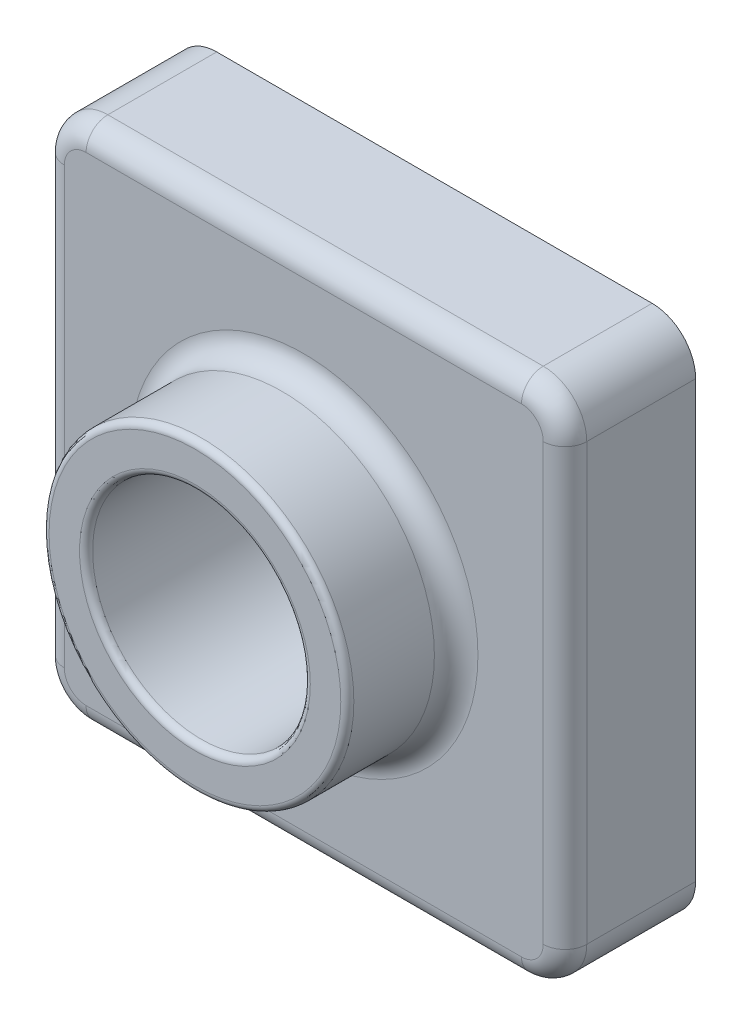
from build123d import *
from OCP.BRepFilletAPI import BRepFilletAPI_MakeFillet

# Parameters (mm, degrees)
SKETCH1_W           = 120
SKETCH1_H           = 120
BOSS_EXTRUDE1_DEPTH = 30
SKETCH3_R           = 35
BOSS_EXTRUDE2_DEPTH = 25
SKETCH4_R           = 25
CUT_EXTRUDE1_DEPTH  = 179.395627749
FILLET1_R1          = 5
FILLET1_R2          = 10
FILLET2_R           = 1.5
SHELL1_T            = -2


with BuildPart() as part:
    # Sketch1 → Boss-Extrude1 (new body)
    with BuildSketch(Plane.XY):
        with Locations((60, 60)):
            Rectangle(SKETCH1_W, SKETCH1_H)
    extrude(amount=BOSS_EXTRUDE1_DEPTH)

    # Sketch3 → Boss-Extrude2 (add)
    with BuildSketch(Plane.XY.offset(30)):
        with Locations((60, 60)):
            Circle(SKETCH3_R)
    extrude(amount=BOSS_EXTRUDE2_DEPTH)

    # Sketch4 → Cut-Extrude1 (cut, through all)
    with BuildSketch(Plane.XY.offset(55)):
        with Locations((60, 60)):
            Circle(SKETCH4_R)
    extrude(amount=-CUT_EXTRUDE1_DEPTH, mode=Mode.SUBTRACT)

    # Fillet1: one fillet with a radius per group of edges: ONE call of the kernel's fillet builder (fillet() takes one radius for all edges)
    fillet1_edges_1 = [part.edges().sort_by_distance(p)[0] for p in [
        (120, 60, 30),
        (25, 60, 30),
        (60, 120, 30),
        (0, 60, 30),
        (60, 0, 30),
    ]]
    fillet1_edges_2 = [part.edges().sort_by_distance(p)[0] for p in [
        (0, 120, 15),
        (120, 120, 15),
        (120, 0, 15),
        (0, 0, 15),
    ]]
    fillet1 = BRepFilletAPI_MakeFillet(part.part.solid().wrapped)
    for e in fillet1_edges_1:
        fillet1.Add(FILLET1_R1, e.wrapped)
    for e in fillet1_edges_2:
        fillet1.Add(FILLET1_R2, e.wrapped)
    add(Compound.cast(fillet1.Shape()), mode=Mode.REPLACE)

    # Fillet2
    fillet2_edges = [part.edges().sort_by_distance(p)[0] for p in [
        (25, 60, 55),
        (35, 60, 55),
    ]]
    fillet(fillet2_edges, radius=FILLET2_R)

    # Shell1
    shell1_openings = [part.faces().sort_by_distance(p)[0] for p in [
        (60, 118.302943725, 0),
    ]]
    offset(amount=SHELL1_T, openings=shell1_openings, kind=Kind.INTERSECTION)


solid = part.part
